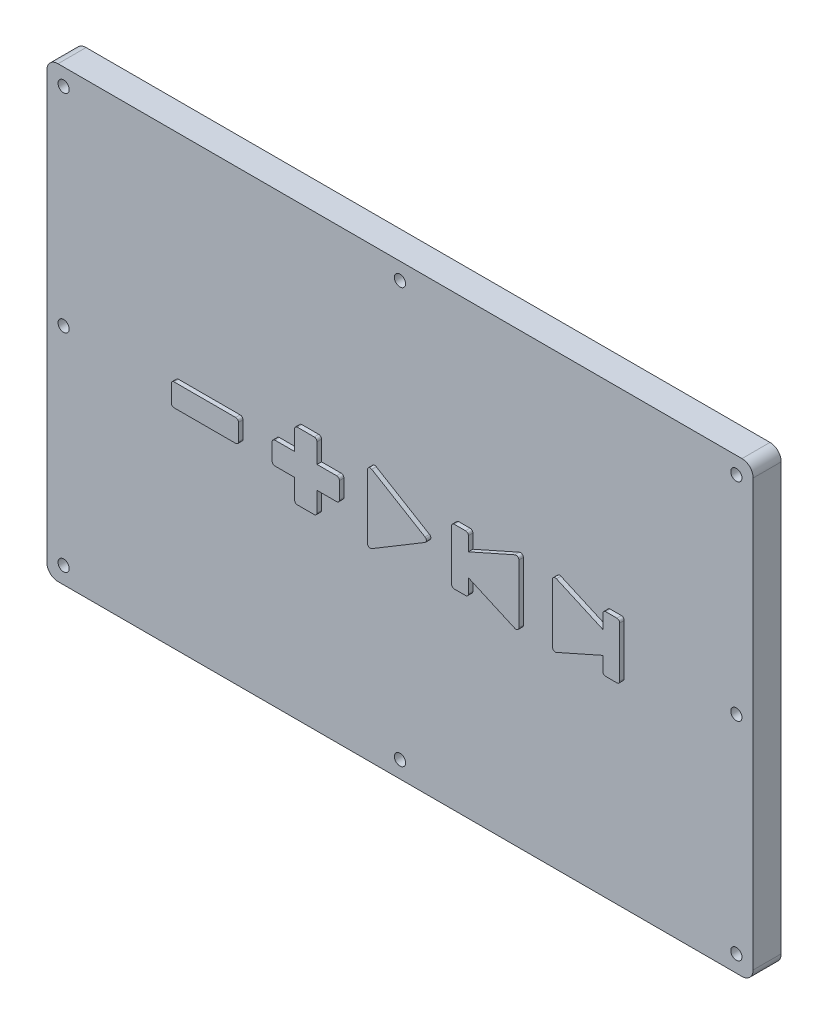
from build123d import *

# Parameters (mm, degrees)
BOSS_EXTRUDE1_DEPTH = 5
BOSS_EXTRUDE2_DEPTH = 0.8
SKETCH22_R          = 0.75
CUT_EXTRUDE1_DEPTH  = 1
SKETCH18_R          = 1
CUT_EXTRUDE2_DEPTH  = 35
SKETCH15_R          = 1
CUT_EXTRUDE3_DEPTH  = 3


with BuildPart() as part:
    # Sketch1 → Boss-Extrude1 (new body)
    with BuildSketch(Plane.XY):
        with BuildLine():
            Line((-61, 40), (61, 40))
            ThreePointArc((61, 40), (62.414213562, 39.414213562), (63, 38))
            Line((63, 38), (63, -38))
            ThreePointArc((63, -38), (62.414213562, -39.414213562), (61, -40))
            Line((61, -40), (-61, -40))
            ThreePointArc((-61, -40), (-62.414213562, -39.414213562), (-63, -38))
            Line((-63, -38), (-63, 38))
            ThreePointArc((-63, 38), (-62.414213562, 39.414213562), (-61, 40))
        make_face()
    extrude(amount=BOSS_EXTRUDE1_DEPTH)

    # Sketch19 → Boss-Extrude2 (add)
    with BuildSketch(Plane.XY.offset(5)):
        with BuildLine():
            Line((-5, 5.7), (-5, -5.7))
            ThreePointArc((-5, -5.7), (-4.746349407, -6.135099953), (-4.242752122, -6.128746463))
            Line((-4.242752122, -6.128746463), (5.257247878, -0.428746463))
            ThreePointArc((5.257247878, -0.428746463), (5.5, 0), (5.257247878, 0.428746463))
            Line((5.257247878, 0.428746463), (-4.242752122, 6.128746463))
            ThreePointArc((-4.242752122, 6.128746463), (-4.746349407, 6.135099953), (-5, 5.7))
        make_face()
        with BuildLine():
            Line((-10, -1.5), (-10, 1.5))
            ThreePointArc((-10, 1.5), (-10.146446609, 1.853553391), (-10.5, 2))
            Line((-10.5, 2), (-14, 2))
            Line((-14, 2), (-14, 5.5))
            ThreePointArc((-14, 5.5), (-14.146446609, 5.853553391), (-14.5, 6))
            Line((-14.5, 6), (-17.5, 6))
            ThreePointArc((-17.5, 6), (-17.853553391, 5.853553391), (-18, 5.5))
            Line((-18, 5.5), (-18, 2))
            Line((-18, 2), (-21.5, 2))
            ThreePointArc((-21.5, 2), (-21.853553391, 1.853553391), (-22, 1.5))
            Line((-22, 1.5), (-22, -1.5))
            ThreePointArc((-22, -1.5), (-21.853553391, -1.853553391), (-21.5, -2))
            Line((-21.5, -2), (-18, -2))
            Line((-18, -2), (-18, -5.5))
            ThreePointArc((-18, -5.5), (-17.853553391, -5.853553391), (-17.5, -6))
            Line((-17.5, -6), (-14.5, -6))
            ThreePointArc((-14.5, -6), (-14.146446609, -5.853553391), (-14, -5.5))
            Line((-14, -5.5), (-14, -2))
            Line((-14, -2), (-10.5, -2))
            ThreePointArc((-10.5, -2), (-10.146446609, -1.853553391), (-10, -1.5))
        make_face()
        with BuildLine():
            Line((-28, 1.5), (-28, -1.5))
            ThreePointArc((-28, -1.5), (-28.146446609, -1.853553391), (-28.5, -2))
            Line((-28.5, -2), (-39.5, -2))
            ThreePointArc((-39.5, -2), (-39.853553391, -1.853553391), (-40, -1.5))
            Line((-40, -1.5), (-40, 1.5))
            ThreePointArc((-40, 1.5), (-39.853553391, 1.853553391), (-39.5, 2))
            Line((-39.5, 2), (-28.5, 2))
            ThreePointArc((-28.5, 2), (-28.146446609, 1.853553391), (-28, 1.5))
        make_face()
        with BuildLine():
            Line((10, 4.5), (10, -4.5))
            ThreePointArc((10, -4.5), (10.146446609, -4.853553391), (10.5, -5))
            Line((10.5, -5), (12.5, -5))
            ThreePointArc((12.5, -5), (12.853553391, -4.853553391), (13, -4.5))
            Line((13, -4.5), (13, -2))
            Line((13, -2), (21.296930767, -5.687524785))
            ThreePointArc((21.296930767, -5.687524785), (21.77245677, -5.64986513), (22, -5.230619011))
            Line((22, -5.230619011), (22, 5.230619011))
            ThreePointArc((22, 5.230619011), (21.77245677, 5.64986513), (21.296930767, 5.687524785))
            Line((21.296930767, 5.687524785), (13, 2))
            Line((13, 2), (13, 4.5))
            ThreePointArc((13, 4.5), (12.853553391, 4.853553391), (12.5, 5))
            Line((12.5, 5), (10.5, 5))
            ThreePointArc((10.5, 5), (10.146446609, 4.853553391), (10, 4.5))
        make_face()
        with BuildLine():
            Line((28, 5.230619011), (28, -5.230619011))
            ThreePointArc((28, -5.230619011), (28.22754323, -5.64986513), (28.703069233, -5.687524785))
            Line((28.703069233, -5.687524785), (37, -2))
            Line((37, -2), (37, -4.5))
            ThreePointArc((37, -4.5), (37.146446609, -4.853553391), (37.5, -5))
            Line((37.5, -5), (39.5, -5))
            ThreePointArc((39.5, -5), (39.853553391, -4.853553391), (40, -4.5))
            Line((40, -4.5), (40, 4.5))
            ThreePointArc((40, 4.5), (39.853553391, 4.853553391), (39.5, 5))
            Line((39.5, 5), (37.5, 5))
            ThreePointArc((37.5, 5), (37.146446609, 4.853553391), (37, 4.5))
            Line((37, 4.5), (37, 2))
            Line((37, 2), (28.703069233, 5.687524785))
            ThreePointArc((28.703069233, 5.687524785), (28.22754323, 5.64986513), (28, 5.230619011))
        make_face()
    extrude(amount=BOSS_EXTRUDE2_DEPTH)

    # Sketch22 → Cut-Extrude1 (cut)
    with BuildSketch(Plane.XY):
        with Locations((-34, 0)):
            Circle(SKETCH22_R)
        with Locations((-16, 0)):
            Circle(SKETCH22_R)
        with Locations((-1, 0)):
            Circle(SKETCH22_R)
        with Locations((17, 0)):
            Circle(SKETCH22_R)
        with Locations((33, 0)):
            Circle(SKETCH22_R)
    extrude(amount=CUT_EXTRUDE1_DEPTH, mode=Mode.SUBTRACT)

    # Sketch18 → Cut-Extrude2 (cut)
    with BuildSketch(Plane.XY):
        with Locations((60, 37)):
            Circle(SKETCH18_R)
        with Locations((60, -37)):
            Circle(SKETCH18_R)
        with Locations((-60, -37)):
            Circle(SKETCH18_R)
        with Locations((-60, 37)):
            Circle(SKETCH18_R)
        with Locations((0, 37)):
            Circle(SKETCH18_R)
        with Locations((0, -37)):
            Circle(SKETCH18_R)
        with Locations((-60, 0)):
            Circle(SKETCH18_R)
        with Locations((60, 0)):
            Circle(SKETCH18_R)
    extrude(amount=CUT_EXTRUDE2_DEPTH, mode=Mode.SUBTRACT)

    # Sketch15 → Cut-Extrude3 (cut)
    with BuildSketch(Plane.XY):
        with Locations((-52.5, -27.5)):
            Circle(SKETCH15_R)
        with Locations((-52.5, 27.5)):
            Circle(SKETCH15_R)
        with Locations((52.5, -27.5)):
            Circle(SKETCH15_R)
        with Locations((52.5, 27.5)):
            Circle(SKETCH15_R)
    extrude(amount=CUT_EXTRUDE3_DEPTH, mode=Mode.SUBTRACT)


solid = part.part
